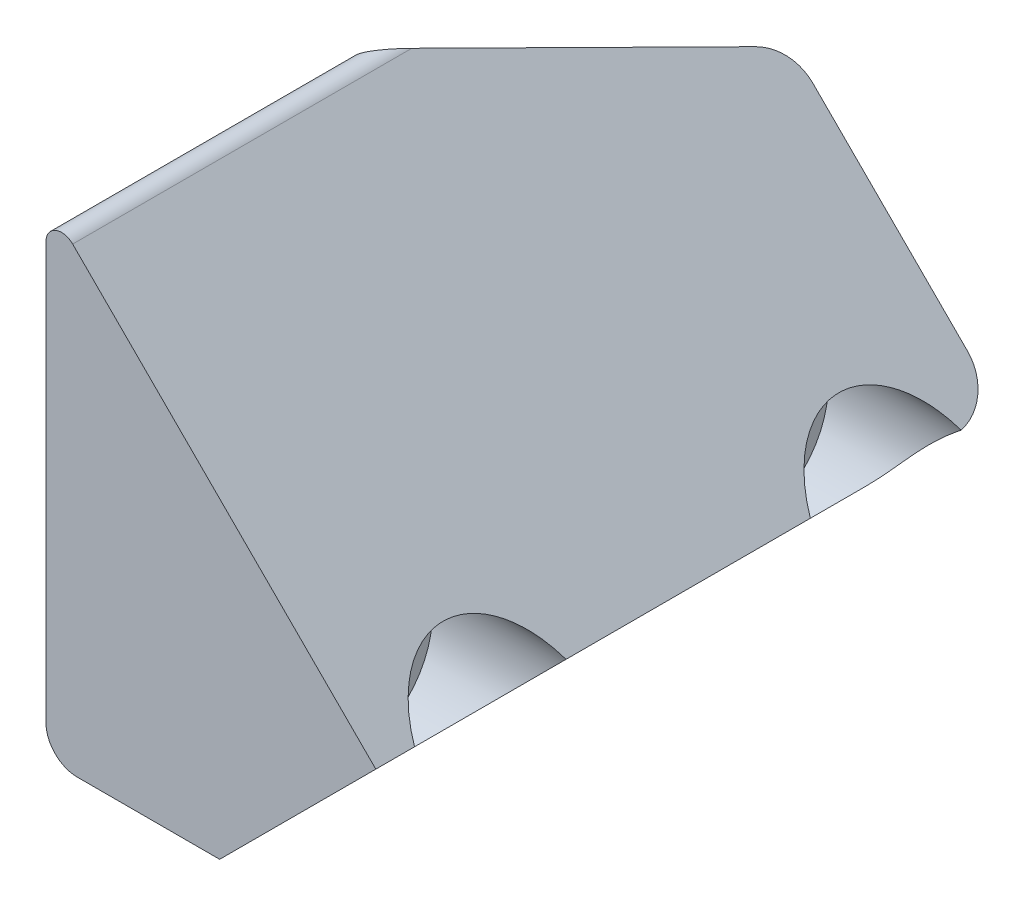
from build123d import *

# Parameters (mm, degrees)
BOSS_EXTRUDE1_DEPTH = 20
SKETCH6_R           = 1.6
CUT_EXTRUDE4_DEPTH  = 16.556349186
SKETCH7_R           = 2.7
CUT_EXTRUDE5_DEPTH  = 10.556349186
FILLET4_R           = 1
FILLET5_R           = 0.5
CUT_EXTRUDE6_DEPTH  = 10
CUT_EXTRUDE7_DEPTH  = 10
FILLET6_R           = 1.5


with BuildPart() as part:
    # Sketch1 → Boss-Extrude1 (new body)
    with BuildSketch(Plane.XY):
        Polygon((0, 0), (0, 15.556349186), (15.556349186, 0), align=None)
    extrude(amount=BOSS_EXTRUDE1_DEPTH)

    # Sketch6 → Cut-Extrude4 (cut, through all)
    with BuildSketch(Plane.ZY):
        with Locations((16.335044769, 3.811593223)):
            Circle(SKETCH6_R)
        with Locations((3.664955231, 3.811593223)):
            Circle(SKETCH6_R)
    extrude(amount=-CUT_EXTRUDE4_DEPTH, mode=Mode.SUBTRACT)

    # Sketch7 → Cut-Extrude5 (cut, through all)
    with BuildSketch(Plane.ZY.offset(-6)):
        with Locations((16.335044769, 3.811593223)):
            Circle(SKETCH7_R)
        with Locations((3.664955231, 3.811593223)):
            Circle(SKETCH7_R)
    extrude(amount=-CUT_EXTRUDE5_DEPTH, mode=Mode.SUBTRACT)

    # Fillet4
    fillet4_edges = [part.edges().sort_by_distance(p)[0] for p in [
        (0, 0, 10),
    ]]
    fillet(fillet4_edges, radius=FILLET4_R)

    # Fillet5
    fillet5_edges = [part.edges().sort_by_distance(p)[0] for p in [
        (0, 15.556349186, 10),
        (15.556349186, 0, 10),
    ]]
    fillet(fillet5_edges, radius=FILLET5_R)

    # Sketch8 → Cut-Extrude6 (cut)
    with BuildSketch(Plane(origin=(7.778174593, 7.778174593, 0), x_dir=(0, 0, -1), z_dir=(0.707106781, 0.707106781, 0))):
        Polygon((-20, -12.333051339), (0, -12.333051339), (0.012190886, -3.93058749), (-20, -3.93058749), align=None)
    extrude(amount=-CUT_EXTRUDE6_DEPTH, mode=Mode.SUBTRACT)

    # Sketch9 → Cut-Extrude7 (cut)
    with BuildSketch(Plane(origin=(7.778174593, 7.778174593, 0), x_dir=(0, 0, -1), z_dir=(0.707106781, 0.707106781, 0))):
        Polygon((-11.323221056, 10.808771842), (0, 5.528667149), (0, 10.808771842), align=None)
    extrude(amount=-CUT_EXTRUDE7_DEPTH, mode=Mode.SUBTRACT)

    # Fillet6
    fillet6_edges = [part.edges().sort_by_distance(p)[0] for p in [
        (8.058104899, 2.499414762, 0),
        (1.934408281, 9.753124344, 0),
    ]]
    fillet(fillet6_edges, radius=FILLET6_R)


solid = part.part
